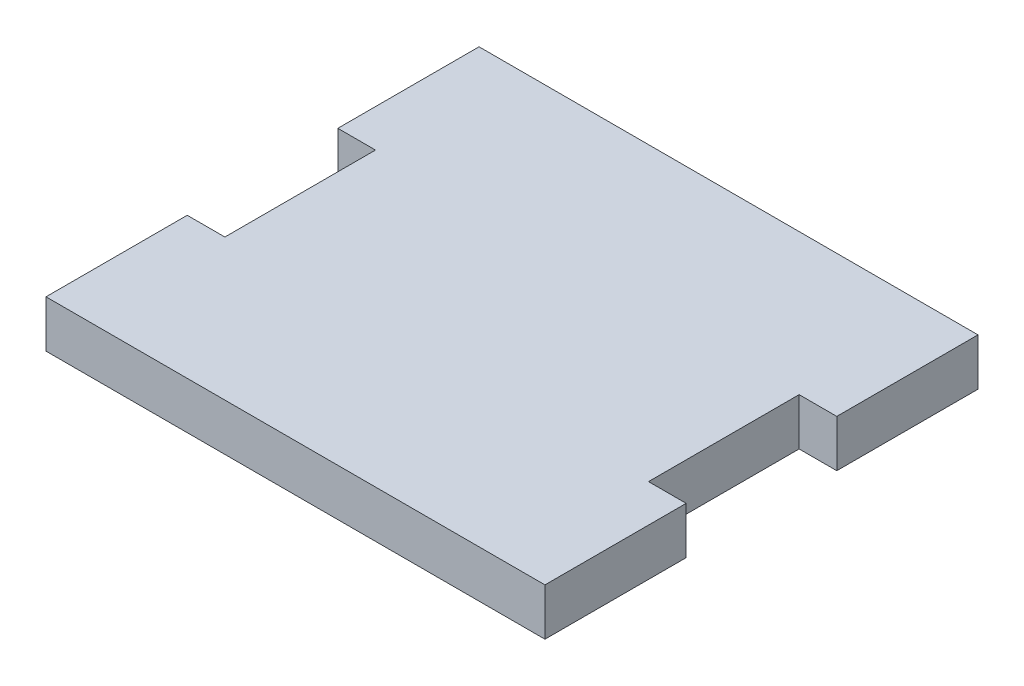
from build123d import *

# Parameters (mm, degrees)
BOSS_EXTRUDE1_DEPTH = 5


with BuildPart() as part:
    # Sketch1 → Boss-Extrude1 (new body)
    with BuildSketch(Plane(origin=(0, 0, 0), x_dir=(1, 0, 0), z_dir=(0, 1, 0))):
        Polygon((-26.5, 23), (-26.5, 8), (-22.5, 8), (-22.5, -8), (-26.5, -8), (-26.5, -23), (26.5, -23), (26.5, -8), (22.5, -8), (22.5, 8), (26.5, 8), (26.5, 23), align=None)
    extrude(amount=BOSS_EXTRUDE1_DEPTH)


solid = part.part
